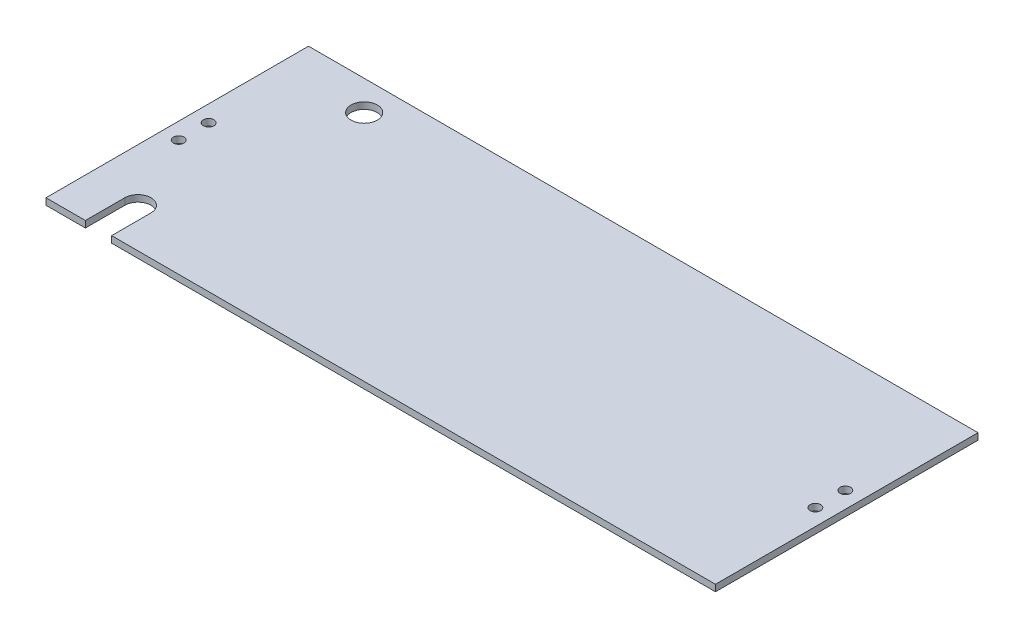
from build123d import *

# Parameters (mm, degrees)
SKETCH1_W                  = 323.85
SKETCH1_H                  = 127
BOSS_EXTRUDE1_DEPTH        = 3.175
SKETCH2_R                  = 6.35
SKETCH2_W                  = 12.7
SKETCH2_H                  = 19.05
CUT_EXTRUDE1_DEPTH         = 4.175
F_10_CLEARANCE_HOLE1_D     = 5.1054
F_10_CLEARANCE_HOLE1_DEPTH = 12.7
F_10_CLEARANCE_HOLE1_TIP   = 1.533816902


with BuildPart() as part:
    # Sketch1 → Boss-Extrude1 (new body)
    with BuildSketch(Plane(origin=(0, 0, 0), x_dir=(1, 0, 0), z_dir=(0, 1, 0))):
        with Locations((161.925, 63.5)):
            Rectangle(SKETCH1_W, SKETCH1_H)
    extrude(amount=BOSS_EXTRUDE1_DEPTH)

    # Sketch2 → Cut-Extrude1 (cut, through all)
    with BuildSketch(Plane(origin=(0, 0, 0), x_dir=(-1, 0, 0), z_dir=(0, -1, 0))):
        with Locations((-41.275, 112.649)):
            Circle(SKETCH2_R)
        with Locations((-25.4, 19.05)):
            Circle(SKETCH2_R)
        with Locations((-25.4, 9.525)):
            Rectangle(SKETCH2_W, SKETCH2_H)
    extrude(amount=-CUT_EXTRUDE1_DEPTH, mode=Mode.SUBTRACT)

    # #10 Clearance Hole1
    with Locations(Plane(origin=(0, 0, 0), x_dir=(-1, 0, 0), z_dir=(0, -1, 0))):
        with Locations((-315.9125, 70.75), (-315.9125, 56.25), (-7.9375, 70.75), (-7.9375, 56.25)):
            Hole(F_10_CLEARANCE_HOLE1_D / 2, depth=F_10_CLEARANCE_HOLE1_DEPTH)
            with Locations((0, 0, -(F_10_CLEARANCE_HOLE1_DEPTH + F_10_CLEARANCE_HOLE1_TIP / 2))):  # 118° drill point
                Cone(0, F_10_CLEARANCE_HOLE1_D / 2, F_10_CLEARANCE_HOLE1_TIP, mode=Mode.SUBTRACT)


solid = part.part
